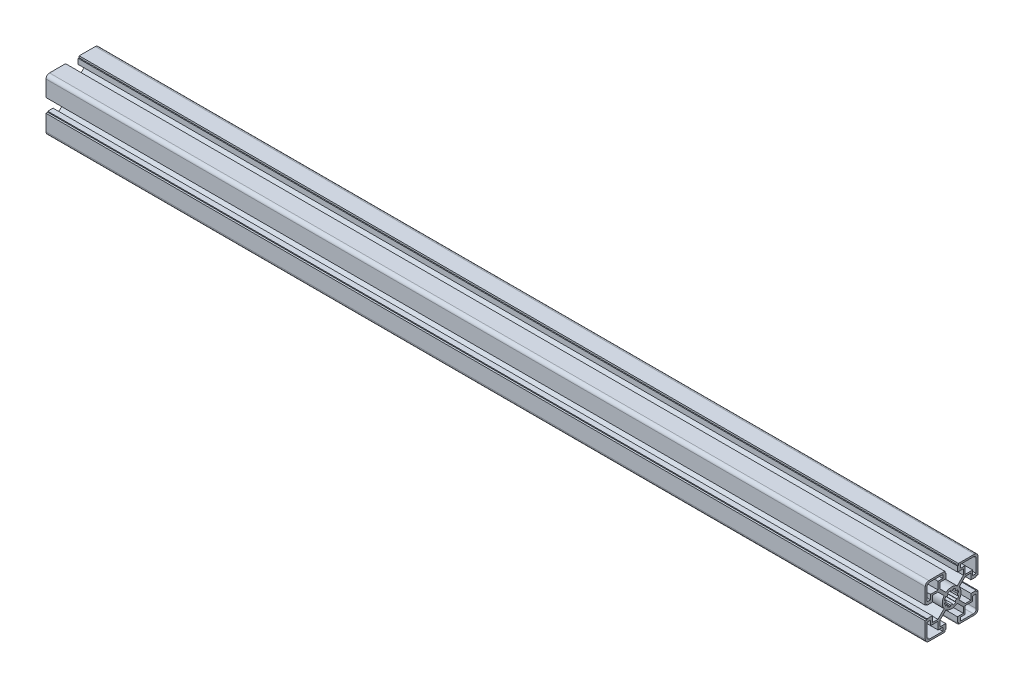
from build123d import *

# Parameters (mm, degrees)
BR_EXTRUDE_DEPTH      = 352.5
BR_EXTRUDE_DEPTH_BACK = 397.5


with BuildPart() as part:
    # Sketch2 → BR_Extrude (new body, two sides)
    with BuildSketch(Plane(origin=(0, 0, 0), x_dir=(0, 0, -1), z_dir=(1, 0, 0))) as br_extrude_sk:
        with BuildLine():
            Line((-10.05, 11.676345597), (-10.05, 16.5))
            Line((-10.05, 16.5), (-5, 16.5))
            Line((-5, 16.5), (-5, 21))
            Line((-5, 21), (-5.8, 21))
            Line((-5.8, 21), (-5.8, 22.5))
            Line((-5.8, 22.5), (-19.5, 22.5))
            ThreePointArc((-19.5, 22.5), (-21.621320344, 21.621320344), (-22.5, 19.5))
            Line((-22.5, 19.5), (-22.5, 5.8))
            Line((-22.5, 5.8), (-21, 5.8))
            Line((-21, 5.8), (-21, 5))
            Line((-21, 5), (-16.5, 5))
            Line((-16.5, 5), (-16.5, 10.05))
            Line((-16.5, 10.05), (-11.676345597, 10.05))
            Line((-11.676345597, 10.05), (-6.411275155, 4.784929559))
            ThreePointArc((-6.411275155, 4.784929559), (-8, 0), (-6.411275155, -4.784929559))
            Line((-6.411275155, -4.784929559), (-11.676345597, -10.05))
            Line((-11.676345597, -10.05), (-16.5, -10.05))
            Line((-16.5, -10.05), (-16.5, -5))
            Line((-16.5, -5), (-21, -5))
            Line((-21, -5), (-21, -5.8))
            Line((-21, -5.8), (-22.5, -5.8))
            Line((-22.5, -5.8), (-22.5, -19.5))
            ThreePointArc((-22.5, -19.5), (-21.621320344, -21.621320344), (-19.5, -22.5))
            Line((-19.5, -22.5), (-5.8, -22.5))
            Line((-5.8, -22.5), (-5.8, -21))
            Line((-5.8, -21), (-5, -21))
            Line((-5, -21), (-5, -16.5))
            Line((-5, -16.5), (-10.05, -16.5))
            Line((-10.05, -16.5), (-10.05, -11.676345597))
            Line((-10.05, -11.676345597), (-4.784929559, -6.411275155))
            ThreePointArc((-4.784929559, -6.411275155), (0, -8), (4.784929559, -6.411275155))
            Line((4.784929559, -6.411275155), (10.05, -11.676345597))
            Line((10.05, -11.676345597), (10.05, -16.5))
            Line((10.05, -16.5), (5, -16.5))
            Line((5, -16.5), (5, -21))
            Line((5, -21), (5.8, -21))
            Line((5.8, -21), (5.8, -22.5))
            Line((5.8, -22.5), (19.5, -22.5))
            ThreePointArc((19.5, -22.5), (21.621320344, -21.621320344), (22.5, -19.5))
            Line((22.5, -19.5), (22.5, -5.8))
            Line((22.5, -5.8), (21, -5.8))
            Line((21, -5.8), (21, -5))
            Line((21, -5), (16.5, -5))
            Line((16.5, -5), (16.5, -10.05))
            Line((16.5, -10.05), (11.676345597, -10.05))
            Line((11.676345597, -10.05), (6.411275155, -4.784929559))
            ThreePointArc((6.411275155, -4.784929559), (8, 0), (6.411275155, 4.784929559))
            Line((6.411275155, 4.784929559), (11.676345597, 10.05))
            Line((11.676345597, 10.05), (16.5, 10.05))
            Line((16.5, 10.05), (16.5, 5))
            Line((16.5, 5), (21, 5))
            Line((21, 5), (21, 5.8))
            Line((21, 5.8), (22.5, 5.8))
            Line((22.5, 5.8), (22.5, 19.5))
            ThreePointArc((22.5, 19.5), (21.621320344, 21.621320344), (19.5, 22.5))
            Line((19.5, 22.5), (5.8, 22.5))
            Line((5.8, 22.5), (5.8, 21))
            Line((5.8, 21), (5, 21))
            Line((5, 21), (5, 16.5))
            Line((5, 16.5), (10.05, 16.5))
            Line((10.05, 16.5), (10.05, 11.676345597))
            Line((10.05, 11.676345597), (4.784929559, 6.411275155))
            ThreePointArc((4.784929559, 6.411275155), (0, 8), (-4.784929559, 6.411275155))
            Line((-4.784929559, 6.411275155), (-10.05, 11.676345597))
        make_face()
        with BuildLine():
            Line((11.55, 11.55), (11.55, 18))
            Line((11.55, 18), (7.5, 18))
            Line((7.5, 18), (7.5, 21))
            Line((7.5, 21), (18.5, 21))
            ThreePointArc((18.5, 21), (20.267766953, 20.267766953), (21, 18.5))
            Line((21, 18.5), (21, 7.5))
            Line((21, 7.5), (18, 7.5))
            Line((18, 7.5), (18, 11.55))
            Line((18, 11.55), (11.55, 11.55))
        make_face(mode=Mode.SUBTRACT)
        with BuildLine():
            Line((11.55, -11.55), (18, -11.55))
            Line((18, -11.55), (18, -7.5))
            Line((18, -7.5), (21, -7.5))
            Line((21, -7.5), (21, -18.5))
            ThreePointArc((21, -18.5), (20.267766953, -20.267766953), (18.5, -21))
            Line((18.5, -21), (7.5, -21))
            Line((7.5, -21), (7.5, -18))
            Line((7.5, -18), (11.55, -18))
            Line((11.55, -18), (11.55, -11.55))
        make_face(mode=Mode.SUBTRACT)
        with BuildLine():
            Line((-11.55, 11.55), (-18, 11.55))
            Line((-18, 11.55), (-18, 7.5))
            Line((-18, 7.5), (-21, 7.5))
            Line((-21, 7.5), (-21, 18.5))
            ThreePointArc((-21, 18.5), (-20.267766953, 20.267766953), (-18.5, 21))
            Line((-18.5, 21), (-7.5, 21))
            Line((-7.5, 21), (-7.5, 18))
            Line((-7.5, 18), (-11.55, 18))
            Line((-11.55, 18), (-11.55, 11.55))
        make_face(mode=Mode.SUBTRACT)
        with BuildLine():
            Line((-11.55, -11.55), (-11.55, -18))
            Line((-11.55, -18), (-7.5, -18))
            Line((-7.5, -18), (-7.5, -21))
            Line((-7.5, -21), (-18.5, -21))
            ThreePointArc((-18.5, -21), (-20.267766953, -20.267766953), (-21, -18.5))
            Line((-21, -18.5), (-21, -7.5))
            Line((-21, -7.5), (-18, -7.5))
            Line((-18, -7.5), (-18, -11.55))
            Line((-18, -11.55), (-11.55, -11.55))
        make_face(mode=Mode.SUBTRACT)
        with BuildLine():
            Line((-6.007327293, -1.059253884), (-4.924038765, -0.868240888))
            ThreePointArc((-4.924038765, -0.868240888), (-5, 0), (-4.924038765, 0.868240888))
            Line((-4.924038765, 0.868240888), (-6.007327293, 1.059253884))
            ThreePointArc((-6.007327293, 1.059253884), (-5.635665148, 2.334368937), (-4.99682747, 3.498816262))
            Line((-4.99682747, 3.498816262), (-4.095760221, 2.867882182))
            ThreePointArc((-4.095760221, 2.867882182), (-3.535533906, 3.535533906), (-2.867882182, 4.095760221))
            Line((-2.867882182, 4.095760221), (-3.498816262, 4.99682747))
            ThreePointArc((-3.498816262, 4.99682747), (-2.334368937, 5.635665148), (-1.059253884, 6.007327293))
            Line((-1.059253884, 6.007327293), (-0.868240888, 4.924038765))
            ThreePointArc((-0.868240888, 4.924038765), (0, 5), (0.868240888, 4.924038765))
            Line((0.868240888, 4.924038765), (1.059253884, 6.007327293))
            ThreePointArc((1.059253884, 6.007327293), (2.334368937, 5.635665148), (3.498816262, 4.99682747))
            Line((3.498816262, 4.99682747), (2.867882182, 4.095760221))
            ThreePointArc((2.867882182, 4.095760221), (3.535533906, 3.535533906), (4.095760221, 2.867882182))
            Line((4.095760221, 2.867882182), (4.99682747, 3.498816262))
            ThreePointArc((4.99682747, 3.498816262), (5.635665148, 2.334368937), (6.007327293, 1.059253884))
            Line((6.007327293, 1.059253884), (4.924038765, 0.868240888))
            ThreePointArc((4.924038765, 0.868240888), (5, 0), (4.924038765, -0.868240888))
            Line((4.924038765, -0.868240888), (6.007327293, -1.059253884))
            ThreePointArc((6.007327293, -1.059253884), (5.635665148, -2.334368937), (4.99682747, -3.498816262))
            Line((4.99682747, -3.498816262), (4.095760221, -2.867882182))
            ThreePointArc((4.095760221, -2.867882182), (3.535533906, -3.535533906), (2.867882182, -4.095760221))
            Line((2.867882182, -4.095760221), (3.498816262, -4.99682747))
            ThreePointArc((3.498816262, -4.99682747), (2.334368937, -5.635665148), (1.059253884, -6.007327293))
            Line((1.059253884, -6.007327293), (0.868240888, -4.924038765))
            ThreePointArc((0.868240888, -4.924038765), (0, -5), (-0.868240888, -4.924038765))
            Line((-0.868240888, -4.924038765), (-1.059253884, -6.007327293))
            ThreePointArc((-1.059253884, -6.007327293), (-2.334368937, -5.635665148), (-3.498816262, -4.99682747))
            Line((-3.498816262, -4.99682747), (-2.867882182, -4.095760221))
            ThreePointArc((-2.867882182, -4.095760221), (-3.535533906, -3.535533906), (-4.095760221, -2.867882182))
            Line((-4.095760221, -2.867882182), (-4.99682747, -3.498816262))
            ThreePointArc((-4.99682747, -3.498816262), (-5.635665148, -2.334368937), (-6.007327293, -1.059253884))
        make_face(mode=Mode.SUBTRACT)
    extrude(amount=BR_EXTRUDE_DEPTH)
    extrude(br_extrude_sk.sketch, amount=-BR_EXTRUDE_DEPTH_BACK)


solid = part.part
